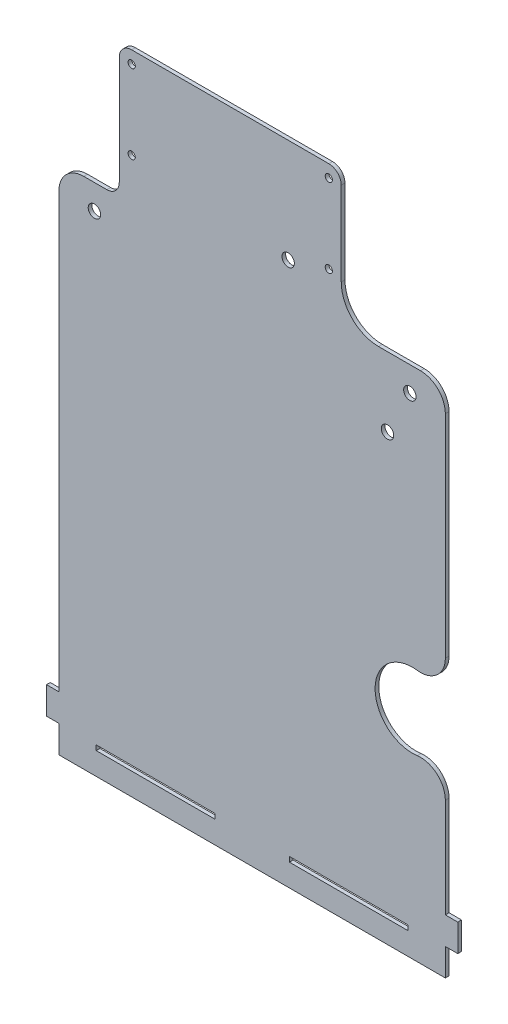
from build123d import *

# Parameters (mm, degrees)
SKETCH1_R           = 2.5
SKETCH1_R_2         = 1.45
BOSS_EXTRUDE1_DEPTH = 1.5
SKETCH2_W           = 47.7875
SKETCH2_H           = 2
CUT_EXTRUDE1_DEPTH  = 2.5


with BuildPart() as part:
    # Sketch1 → Boss-Extrude1 (new body)
    with BuildSketch(Plane.XY):
        with BuildLine():
            Line((24.2875, 244.4875), (24.2875, 200.7375))
            ThreePointArc((24.2875, 200.7375), (22.823033906, 197.201966094), (19.2875, 195.7375))
            Line((19.2875, 195.7375), (10, 195.7375))
            ThreePointArc((10, 195.7375), (2.928932188, 192.808567812), (0, 185.7375))
            Line((0, 185.7375), (0, 11))
            Line((0, 11), (-5, 11))
            Line((-5, 11), (-5, 0))
            Line((-5, 0), (0, 0))
            Line((0, 0), (0, -11))
            Line((0, -11), (155.575, -11))
            Line((155.575, -11), (155.575, 0))
            Line((155.575, 0), (160.575, 0))
            Line((160.575, 0), (160.575, 11))
            Line((160.575, 11), (155.575, 11))
            Line((155.575, 11), (155.575, 50.954595736))
            ThreePointArc((155.575, 50.954595736), (152.164764791, 58.476231197), (144.26, 60.867757442))
            ThreePointArc((144.26, 60.867757442), (127.2875, 75.7375), (144.26, 90.607242558))
            ThreePointArc((144.26, 90.607242558), (152.164764791, 92.998768803), (155.575, 100.520404264))
            Line((155.575, 100.520404264), (155.575, 185.7375))
            ThreePointArc((155.575, 185.7375), (152.646067812, 192.808567812), (145.575, 195.7375))
            Line((145.575, 195.7375), (128.6625, 195.7375))
            ThreePointArc((128.6625, 195.7375), (118.055898282, 200.130898282), (113.6625, 210.7375))
            Line((113.6625, 210.7375), (113.6625, 244.4875))
            ThreePointArc((113.6625, 244.4875), (112.198033906, 248.023033906), (108.6625, 249.4875))
            Line((108.6625, 249.4875), (29.2875, 249.4875))
            ThreePointArc((29.2875, 249.4875), (25.751966094, 248.023033906), (24.2875, 244.4875))
        make_face()
        with Locations((14.2875, 185.7375)):
            Circle(SKETCH1_R, mode=Mode.SUBTRACT)
        with Locations((141.2875, 185.7375)):
            Circle(SKETCH1_R, mode=Mode.SUBTRACT)
        with Locations((108.6625, 212.7375)):
            Circle(SKETCH1_R_2, mode=Mode.SUBTRACT)
        with Locations((108.6625, 244.4875)):
            Circle(SKETCH1_R_2, mode=Mode.SUBTRACT)
        with Locations((29.2875, 244.4875)):
            Circle(SKETCH1_R_2, mode=Mode.SUBTRACT)
        with Locations((29.2875, 212.7375)):
            Circle(SKETCH1_R_2, mode=Mode.SUBTRACT)
        with Locations((132.2875, 167.7375)):
            Circle(SKETCH1_R, mode=Mode.SUBTRACT)
        with Locations((92.2875, 207.7375)):
            Circle(SKETCH1_R, mode=Mode.SUBTRACT)
    extrude(amount=BOSS_EXTRUDE1_DEPTH)

    # Sketch2 → Cut-Extrude1 (cut, through all)
    with BuildSketch(Plane.XY.offset(1.5)):
        with Locations((38.89375, -1)):
            Rectangle(SKETCH2_W, SKETCH2_H)
        with Locations((116.68125, -1)):
            Rectangle(SKETCH2_W, SKETCH2_H)
    extrude(amount=-CUT_EXTRUDE1_DEPTH, mode=Mode.SUBTRACT)


solid = part.part
